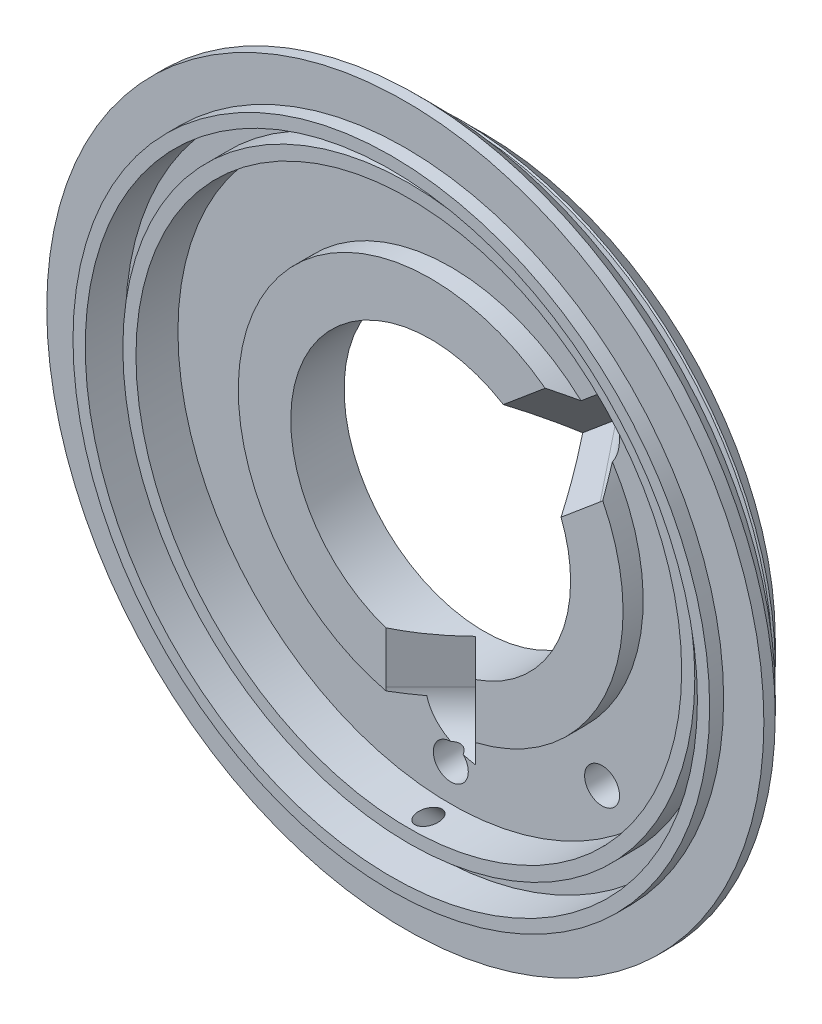
from build123d import *

# Parameters (mm, degrees)
SKETCH1_R                    = 20.5
BOSS_EXTRUDE1_DEPTH          = 5.3
SKETCH4_R                    = 8
CUT_EXTRUDE1_DEPTH           = 6.3
SKETCH6_W                    = 0.8
SKETCH6_H                    = 2.3
CUT_EXTRUDE2_DEPTH           = 10.5
CIRPATTERN3_COUNT            = 2
CIRPATTERN3_ANGLE            = 130
F_2_0_2_DIAMETER_HOLE1_D     = 2
F_2_0_2_DIAMETER_HOLE1_DEPTH = 1.9
M1_4X0_3_TAPPED_HOLE1_D      = 1.1
SKETCH41_R                   = 2.5
CUT_EXTRUDE9_DEPTH           = 3.626346
CIRPATTERN11_COUNT           = 2
CIRPATTERN11_ANGLE           = 130


with BuildPart() as part:
    # Sketch1 → Boss-Extrude1 (new body)
    with BuildSketch(Plane.XY):
        Circle(SKETCH1_R)
    extrude(amount=-BOSS_EXTRUDE1_DEPTH)

    # Sketch4 → Cut-Extrude1 (cut, through all)
    with BuildSketch(Plane.XY):
        Circle(SKETCH4_R)
    extrude(amount=-CUT_EXTRUDE1_DEPTH, mode=Mode.SUBTRACT)

    # Sketch3 → Cut-Revolve1 (revolve, cut)
    with BuildSketch(Plane(origin=(0, 0, 0), x_dir=(0, 0, -1), z_dir=(1, 0, 0))):
        Polygon((2.25, 0), (2.25, -11), (3.4, -11), (3.4, -15.6), (1, -15.6), (1, -16.35), (2.3, -16.35), (2.3, -17.5), (0, -17.5), (0, 0), align=None)
    revolve(axis=Axis((0, 0, 0), (0, 0, -1)), mode=Mode.SUBTRACT)

    # Sketch6 → Cut-Revolve2 (revolve, cut)
    with BuildSketch(Plane(origin=(0, 0, 0), x_dir=(0, 0, -1), z_dir=(1, 0, 0))):
        with Locations((0.4, -19.35)):
            Rectangle(SKETCH6_W, SKETCH6_H)
        Polygon((5.3, -16.65), (1.45, -20.5), (5.3, -20.5), align=None)
    revolve(axis=Axis((0, 0, 0), (0, 0, -1)), mode=Mode.SUBTRACT)

    # Sketch7 → Cut-Revolve3 (revolve, cut)
    with BuildSketch(Plane(origin=(0, 0, 0), x_dir=(0, 0, -1), z_dir=(1, 0, 0))):
        Polygon((1.623044738, 19.195584412), (3.602943725, 17.215685425), (3.809998961, 17.988426086), (3.885786438, 18.064213562), (2.471572875, 19.478427125), (2.395785399, 19.402639648), align=None)
    revolve(axis=Axis((0, 0, 0), (0, 0, -1)), mode=Mode.SUBTRACT)

    # Sketch12 → Cut-Extrude2 (cut)
    with BuildSketch(Plane(origin=(0, 0, 0), x_dir=(1, 0, 0), z_dir=(0, 1, 0))):
        Polygon((0, 4.814213562), (-2.564213562, 2.25), (2.564213562, 2.25), align=None)
    cut_extrude2 = extrude(amount=-CUT_EXTRUDE2_DEPTH, mode=Mode.SUBTRACT)

    # CirPattern3: Cut-Extrude2 ×2 about axis
    cirpattern3_axis = Axis((0, 0, 0), (0, 0, 1))
    for i in range(1, CIRPATTERN3_COUNT):
        add(cut_extrude2.rotate(cirpattern3_axis, i * CIRPATTERN3_ANGLE / (CIRPATTERN3_COUNT - 1)), mode=Mode.SUBTRACT)

    # 2.0 _2_ Diameter Hole1
    with Locations(Plane.XY.offset(-3.4)):
        with Locations((0, -13.5), (8.649447154, -10.365185185)):
            Hole(F_2_0_2_DIAMETER_HOLE1_D / 2, depth=F_2_0_2_DIAMETER_HOLE1_DEPTH)

    # Sketch26 → Cut-Revolve4 (revolve, cut)
    with BuildSketch(Plane(origin=(0, 0, 0), x_dir=(0, 0, -1), z_dir=(1, 0, 0))):
        Polygon((5.158578644, -16.791421356), (4.522182541, -16.155025253), (3.685666237, -16.379169121), (3.296757507, -16.768077851), (4.239339828, -17.710660172), align=None)
    revolve(axis=Axis((0, -16.508472243, -3.037151899), (0, -0.707106781, -0.707106781)), mode=Mode.SUBTRACT)

    # M1.4x0.3 Tapped Hole1 (through all)
    with Locations(Plane(origin=(0, -10.032417679, -10.032417679), x_dir=(-1, 0, 0), z_dir=(0, -0.707106781, -0.707106781))):
        with Locations((0, -9.525661966)):
            Hole(M1_4X0_3_TAPPED_HOLE1_D / 2)

    # Sketch41 → Cut-Extrude9 (cut)
    with BuildSketch(Plane(origin=(-1.547258414, 1.843950774, -2.407106781), x_dir=(0.890736799, 0.276402568, -0.360817927), z_dir=(0.454519478, -0.54167522, 0.707106781))):
        with Locations((9.491497809, 4.580281669)):
            Circle(SKETCH41_R)
    cut_extrude9 = extrude(amount=CUT_EXTRUDE9_DEPTH, mode=Mode.SUBTRACT)

    # CirPattern11: Cut-Extrude9 ×2 about axis
    cirpattern11_axis = Axis((0, 0, 0), (0, 0, -1))
    for i in range(1, CIRPATTERN11_COUNT):
        add(cut_extrude9.rotate(cirpattern11_axis, i * CIRPATTERN11_ANGLE / (CIRPATTERN11_COUNT - 1)), mode=Mode.SUBTRACT)


solid = part.part
